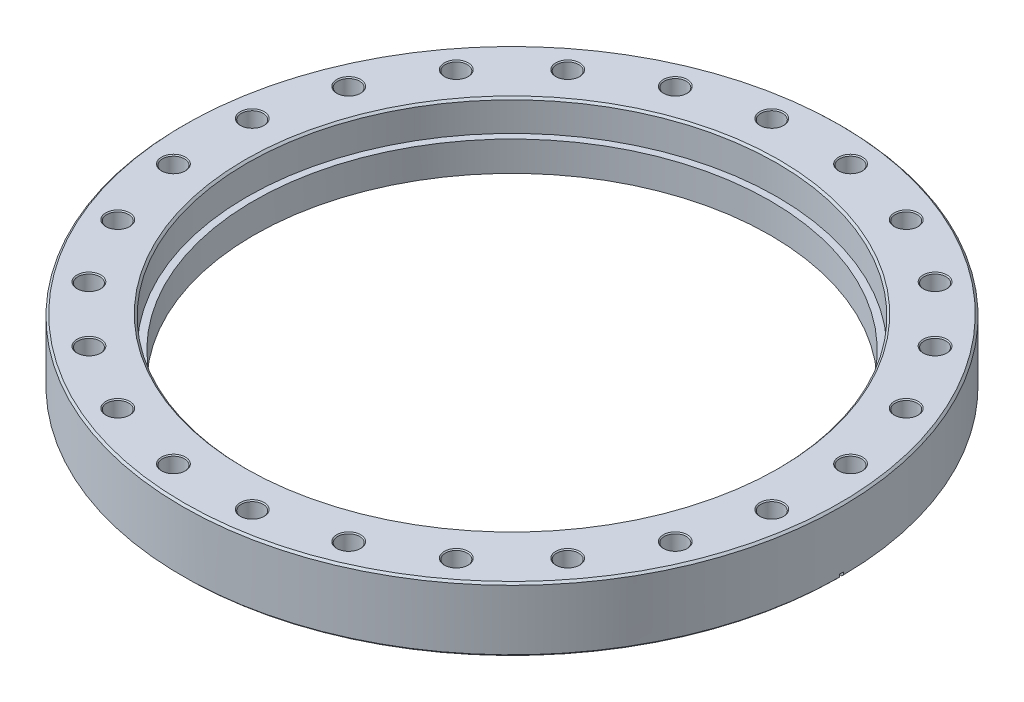
from build123d import *

# Parameters (mm, degrees)
SKETCH1_R                    = 126.619
SKETCH1_R_2                  = 99.2124
BOSS_EXTRUDE1_DEPTH          = 24.638
SKETCH2_R                    = 101.854
CUT_EXTRUDE1_DEPTH           = 11.938
CHAMFER1_SIZE                = 0.762
SKETCH3_R                    = 4.2164
CUT_EXTRUDE2_DEPTH           = 25.638
CHAMFER2_SIZE                = 0.381
CIRPATTERN1_COUNT            = 24
CHAMFER2_OF_CIRPATTERN1_SIZE = 0.381
CUT_EXTRUDE3_DEPTH           = 0.79375


with BuildPart() as part:
    # Sketch1 → Boss-Extrude1 (new body)
    with BuildSketch(Plane(origin=(0, 0, 0), x_dir=(1, 0, 0), z_dir=(0, 1, 0))):
        Circle(SKETCH1_R)
        Circle(SKETCH1_R_2, mode=Mode.SUBTRACT)
    extrude(amount=BOSS_EXTRUDE1_DEPTH)

    # Sketch2 → Cut-Extrude1 (cut)
    with BuildSketch(Plane(origin=(0, 24.638, 0), x_dir=(-1, 0, 0), z_dir=(0, -1, 0))):
        Circle(SKETCH2_R)
    extrude(amount=CUT_EXTRUDE1_DEPTH, mode=Mode.SUBTRACT)

    # Chamfer1
    chamfer1_edges = [part.edges().sort_by_distance(p)[0] for p in [
        (101.854, 24.638, 0),
        (-126.619, 0, 0),
        (-126.619, 24.638, 0),
    ]]
    chamfer(chamfer1_edges, length=CHAMFER1_SIZE)

    # Sketch4 → Cut-Revolve1 (revolve, cut)
    with BuildSketch(Plane.XY):
        Polygon((-111.125, 0), (-111.125, 1.6256), (-108.458, 0.6604), (-108.458, 1.27), (0, 1.27), (0, 0), align=None)
    revolve(axis=Axis((0, 24.638, 0), (0, -1, 0)), mode=Mode.SUBTRACT)

    # Sketch3 → Cut-Extrude2 (cut, through all)
    with BuildSketch(Plane(origin=(0, 24.638, 0), x_dir=(1, 0, 0), z_dir=(0, 1, 0))):
        with Locations((-15.131327149, 114.933840422)):
            Circle(SKETCH3_R)
    cut_extrude2 = extrude(amount=-CUT_EXTRUDE2_DEPTH, mode=Mode.SUBTRACT)

    # Chamfer2
    chamfer2_edges = [part.edges().sort_by_distance(p)[0] for p in [
        (-19.347727149, 0, -114.933840422),
        (-19.347727149, 24.638, -114.933840422),
    ]]
    chamfer(chamfer2_edges, length=CHAMFER2_SIZE)

    # CirPattern1: Cut-Extrude2 ×24 about axis
    cirpattern1_axis = Axis((0, 0, 0), (0, 1, 0))
    for i in range(1, CIRPATTERN1_COUNT):
        add(cut_extrude2.rotate(cirpattern1_axis, i * 360 / CIRPATTERN1_COUNT), mode=Mode.SUBTRACT)

    # Chamfer2 of CirPattern1
    chamfer2_of_cirpattern1_edges = [part.edges().sort_by_distance(p)[0] for p in [
        (-48.435536161, 0, -106.010004512),
        (-48.435536161, 24.638, -106.010004512),
        (-74.222543427, 0, -89.861761985),
        (-74.222543427, 24.638, -89.861761985),
        (-94.951407017, 0, -67.589588882),
        (-94.951407017, 24.638, -67.589588882),
        (-109.209489134, 0, -40.711296994),
        (-109.209489134, 24.638, -40.711296994),
        (-116.025125043, 0, -11.058597495),
        (-116.025125043, 24.638, -11.058597495),
        (-114.933840422, 0, 19.347727149),
        (-114.933840422, 24.638, 19.347727149),
        (-106.010004512, 0, 48.435536161),
        (-106.010004512, 24.638, 48.435536161),
        (-89.861761985, 0, 74.222543427),
        (-89.861761985, 24.638, 74.222543427),
        (-67.589588882, 0, 94.951407017),
        (-67.589588882, 24.638, 94.951407017),
        (-40.711296994, 0, 109.209489134),
        (-40.711296994, 24.638, 109.209489134),
        (-11.058597495, 0, 116.025125043),
        (-11.058597495, 24.638, 116.025125043),
        (19.347727149, 0, 114.933840422),
        (19.347727149, 24.638, 114.933840422),
        (48.435536161, 0, 106.010004512),
        (48.435536161, 24.638, 106.010004512),
        (74.222543427, 0, 89.861761985),
        (74.222543427, 24.638, 89.861761985),
        (94.951407017, 0, 67.589588882),
        (94.951407017, 24.638, 67.589588882),
        (109.209489134, 0, 40.711296994),
        (109.209489134, 24.638, 40.711296994),
        (116.025125043, 0, 11.058597495),
        (116.025125043, 24.638, 11.058597495),
        (114.933840422, 0, -19.347727149),
        (114.933840422, 24.638, -19.347727149),
        (106.010004512, 0, -48.435536161),
        (106.010004512, 24.638, -48.435536161),
        (89.861761985, 0, -74.222543427),
        (89.861761985, 24.638, -74.222543427),
        (67.589588882, 0, -94.951407017),
        (67.589588882, 24.638, -94.951407017),
        (40.711296994, 0, -109.209489134),
        (40.711296994, 24.638, -109.209489134),
        (11.058597495, 0, -116.025125043),
        (11.058597495, 24.638, -116.025125043),
    ]]
    chamfer(chamfer2_of_cirpattern1_edges, length=CHAMFER2_OF_CIRPATTERN1_SIZE)

    # Sketch5 → Cut-Extrude3 (cut, symmetric)
    with BuildSketch(Plane.XY):
        Polygon((-109.62454103, 0.887787398), (-126.619, 1.778429253), (-126.619, -4.857391352), (-109.62454103, -4.857391352), align=None)
        Polygon((109.62454103, 0.887787398), (109.62454103, -4.857391352), (126.619, -4.857391352), (126.619, 1.778429253), align=None)
    extrude(amount=CUT_EXTRUDE3_DEPTH, both=True, mode=Mode.SUBTRACT)


solid = part.part
